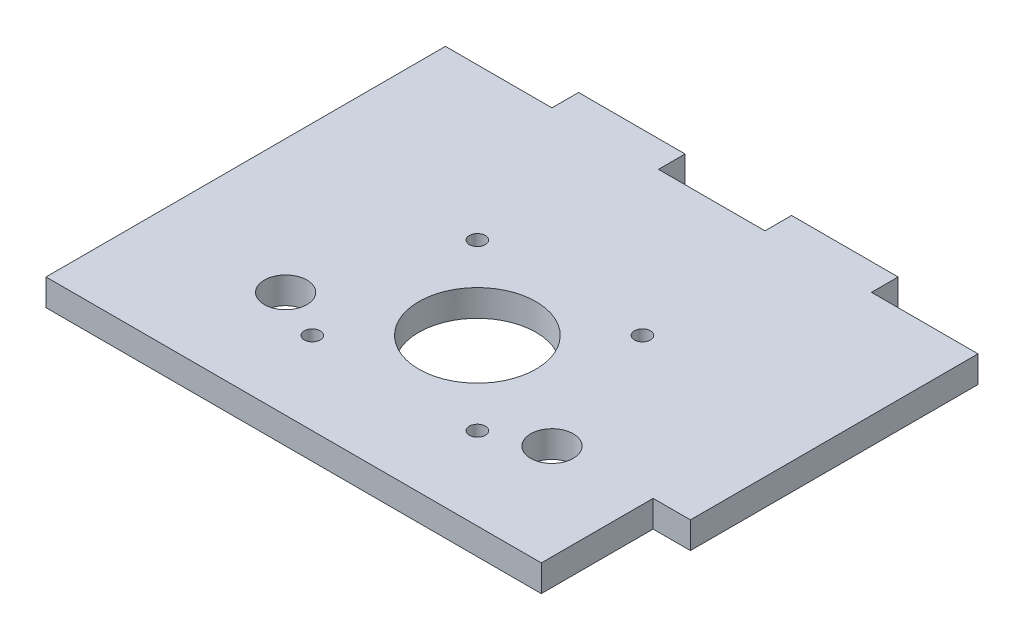
from build123d import *

# Parameters (mm, degrees)
SKETCH1_R           = 4
SKETCH1_R_2         = 1.5
BOSS_EXTRUDE1_DEPTH = 5
CUT_EXTRUDE1_REACH  = 7
SKETCH2_R           = 11
SKETCH3_W           = 21
SKETCH3_H           = 5
CUT_EXTRUDE2_DEPTH  = 7


with BuildPart() as part:
    # Sketch1 → Boss-Extrude1 (new body)
    with BuildSketch(Plane(origin=(0, 0, 0), x_dir=(1, 0, 0), z_dir=(0, 1, 0))):
        Polygon((-50, 44), (-30, 44), (-30, 49), (-10, 49), (-10, 44), (10, 44), (10, 49), (30, 49), (30, 44), (50, 44), (50, -31), (-50, -31), align=None)
        Circle(SKETCH1_R, mode=Mode.SUBTRACT)
        with Locations((15.5, 15.5)):
            Circle(SKETCH1_R_2, mode=Mode.SUBTRACT)
        with Locations((-15.5, 15.5)):
            Circle(SKETCH1_R_2, mode=Mode.SUBTRACT)
        with Locations((-15.5, -15.5)):
            Circle(SKETCH1_R_2, mode=Mode.SUBTRACT)
        with Locations((15.5, -15.5)):
            Circle(SKETCH1_R_2, mode=Mode.SUBTRACT)
        with Locations((-25, -11)):
            Circle(SKETCH1_R, mode=Mode.SUBTRACT)
        with Locations((25, -11)):
            Circle(SKETCH1_R, mode=Mode.SUBTRACT)
    extrude(amount=BOSS_EXTRUDE1_DEPTH)

    # Sketch2 → Cut-Extrude1 (cut, up to next)
    with BuildSketch(Plane(origin=(0, 5, 0), x_dir=(1, 0, 0), z_dir=(0, 1, 0)), mode=Mode.PRIVATE) as cut_extrude1_sk1:
        Circle(SKETCH2_R)
    cut_extrude1_tool1 = extrude(cut_extrude1_sk1.sketch, amount=-CUT_EXTRUDE1_REACH, mode=Mode.PRIVATE) & part.part
    add(cut_extrude1_tool1.solids().sort_by_distance((0, 5, 0))[0], mode=Mode.SUBTRACT)

    # Sketch3 → Cut-Extrude2 (cut)
    with BuildSketch(Plane(origin=(50, 0, 0), x_dir=(0, 0, -1), z_dir=(1, 0, 0))):
        with Locations((-20.5, 2.5)):
            Rectangle(SKETCH3_W, SKETCH3_H)
    extrude(amount=-CUT_EXTRUDE2_DEPTH, mode=Mode.SUBTRACT)


solid = part.part
